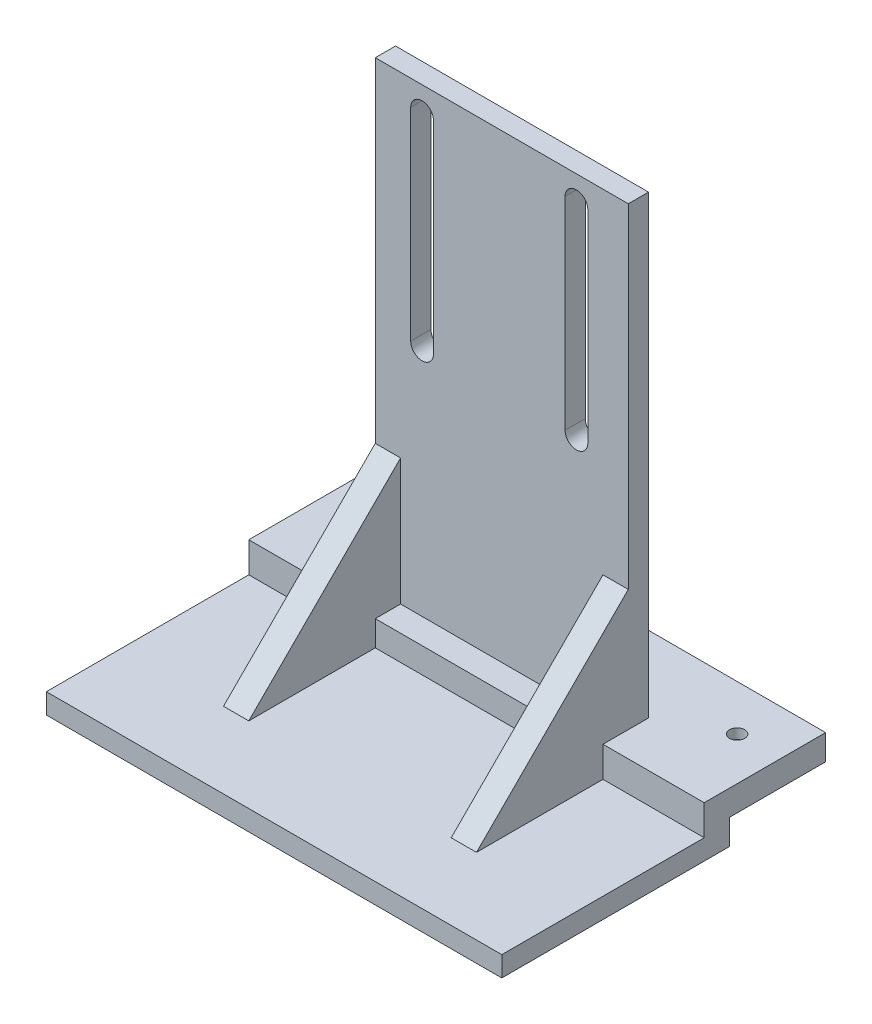
from build123d import *

# Parameters (mm, degrees)
ESQUISSE1_W             = 50
ESQUISSE1_H             = 95
BOSS_EXTRU_1_DEPTH      = 4
ESQUISSE2_W             = 50
ESQUISSE2_H             = 4
BOSS_EXTRU_2_DEPTH      = 5
ESQUISSE3_W             = 50
ESQUISSE3_H             = 5
BOSS_EXTRU_3_DEPTH      = 5
ESQUISSE4_W             = 50
ESQUISSE4_H             = 4
BOSS_EXTRU_4_DEPTH      = 40
ESQUISSE5_W             = 50
ESQUISSE5_H             = 5
BOSS_EXTRU_5_DEPTH      = 15
ENL_V_MAT_EXTRU_1_REACH = 21
BOSS_EXTRU_6_DEPTH      = 5
BOSS_EXTRU_7_DEPTH      = 5
BOSS_EXTRU_8_DEPTH      = 20
BOSS_EXTRU_9_DEPTH      = 20
ENL_V_MAT_EXTRU_2_REACH = 12
ESQUISSE12_R            = 1.5
ESQUISSE13_R            = 2
ENL_V_MAT_EXTRU_3_DEPTH = 3


with BuildPart() as part:
    # Esquisse1 → Boss.-Extru.1 (new body)
    with BuildSketch(Plane.XY):
        with Locations((-4.39396009, -13.572795505)):
            Rectangle(ESQUISSE1_W, ESQUISSE1_H)
    extrude(amount=BOSS_EXTRU_1_DEPTH)

    # Esquisse2 → Boss.-Extru.2 (add)
    with BuildSketch(Plane.XY.offset(4)):
        with Locations((-4.39396009, -59.072795505)):
            Rectangle(ESQUISSE2_W, ESQUISSE2_H)
    extrude(amount=BOSS_EXTRU_2_DEPTH)

    # Esquisse3 → Boss.-Extru.3 (add)
    with BuildSketch(Plane.XZ.offset(61.072795505)):
        with Locations((-4.39396009, 6.5)):
            Rectangle(ESQUISSE3_W, ESQUISSE3_H)
    extrude(amount=BOSS_EXTRU_3_DEPTH)

    # Esquisse4 → Boss.-Extru.4 (add)
    with BuildSketch(Plane.XY.offset(9)):
        with Locations((-4.39396009, -64.072795505)):
            Rectangle(ESQUISSE4_W, ESQUISSE4_H)
    extrude(amount=BOSS_EXTRU_4_DEPTH)

    # Esquisse5 → Boss.-Extru.5 (add)
    with BuildSketch(Plane(origin=(0, 0, 0), x_dir=(-1, 0, 0), z_dir=(0, 0, -1))):
        with Locations((4.39396009, -58.572795505)):
            Rectangle(ESQUISSE5_W, ESQUISSE5_H)
    extrude(amount=BOSS_EXTRU_5_DEPTH)

    # Esquisse6 → Enlèv. mat.-Extru.1 (cut, up to next)
    with BuildSketch(Plane.XY.offset(4), mode=Mode.PRIVATE) as enl_v_mat_extru_1_sk1:
        with BuildLine():
            Line((-17.89396009, 28.927204495), (-17.89396009, -11.072795505))
            ThreePointArc((-17.89396009, -11.072795505), (-20.14396009, -13.322795505), (-22.39396009, -11.072795505))
            Line((-22.39396009, -11.072795505), (-22.39396009, 28.927204495))
            ThreePointArc((-22.39396009, 28.927204495), (-20.14396009, 31.177204495), (-17.89396009, 28.927204495))
        make_face()
    enl_v_mat_extru_1_tool1 = extrude(enl_v_mat_extru_1_sk1.sketch, amount=-ENL_V_MAT_EXTRU_1_REACH, mode=Mode.PRIVATE) & part.part
    add(enl_v_mat_extru_1_tool1.solids().sort_by_distance((-20.14396, 8.927204, 4))[0], mode=Mode.SUBTRACT)
    # Esquisse6 → Enlèv. mat.-Extru.1 (cut, up to next)
    with BuildSketch(Plane.XY.offset(4), mode=Mode.PRIVATE) as enl_v_mat_extru_1_sk2:
        with BuildLine():
            Line((12.60603991, 28.927204495), (12.60603991, -11.072795505))
            ThreePointArc((12.60603991, -11.072795505), (10.35603991, -13.322795505), (8.10603991, -11.072795505))
            Line((8.10603991, -11.072795505), (8.10603991, 28.927204495))
            ThreePointArc((8.10603991, 28.927204495), (10.35603991, 31.177204495), (12.60603991, 28.927204495))
        make_face()
    enl_v_mat_extru_1_tool2 = extrude(enl_v_mat_extru_1_sk2.sketch, amount=-ENL_V_MAT_EXTRU_1_REACH, mode=Mode.PRIVATE) & part.part
    add(enl_v_mat_extru_1_tool2.solids().sort_by_distance((10.35604, 8.927204, 4))[0], mode=Mode.SUBTRACT)

    # Esquisse7 → Boss.-Extru.6 (add)
    with BuildSketch(Plane.ZY.offset(29.39396009)):
        Polygon((4, -32.072795505), (34, -62.072795505), (4, -62.072795505), align=None)
    extrude(amount=-BOSS_EXTRU_6_DEPTH)

    # Esquisse8 → Boss.-Extru.7 (add)
    with BuildSketch(Plane(origin=(20.60603991, 0, 0), x_dir=(0, 0, -1), z_dir=(1, 0, 0))):
        Polygon((-4, -32.072795505), (-34, -62.072795505), (-4, -62.072795505), align=None)
    extrude(amount=-BOSS_EXTRU_7_DEPTH)

    # Esquisse10 → Boss.-Extru.8 (add)
    with BuildSketch(Plane(origin=(20.60603991, 0, 0), x_dir=(0, 0, -1), z_dir=(1, 0, 0))):
        Polygon((-49, -62.072795505), (-49, -66.072795505), (-4, -66.072795505), (-4, -61.072795505), (15, -61.072795505), (15, -56.072795505), (0, -56.072795505), (-9, -56.072795505), (-9, -62.072795505), align=None)
    extrude(amount=BOSS_EXTRU_8_DEPTH)

    # Esquisse11 → Boss.-Extru.9 (add)
    with BuildSketch(Plane.ZY.offset(29.39396009)):
        Polygon((49, -66.072795505), (4, -66.072795505), (4, -61.072795505), (-15, -61.072795505), (-15, -56.072795505), (0, -56.072795505), (9, -56.072795505), (9, -62.072795505), (49, -62.072795505), align=None)
    extrude(amount=BOSS_EXTRU_9_DEPTH)

    # Esquisse12 → Enlèv. mat.-Extru.2 (cut, up to next)
    with BuildSketch(Plane(origin=(0, -56.072795505, 0), x_dir=(1, 0, 0), z_dir=(0, 1, 0)), mode=Mode.PRIVATE) as enl_v_mat_extru_2_sk1:
        with Locations((32.10603991, 6)):
            Circle(ESQUISSE12_R)
    enl_v_mat_extru_2_tool1 = extrude(enl_v_mat_extru_2_sk1.sketch, amount=-ENL_V_MAT_EXTRU_2_REACH, mode=Mode.PRIVATE) & part.part
    add(enl_v_mat_extru_2_tool1.solids().sort_by_distance((32.10604, -56.072796, -6))[0], mode=Mode.SUBTRACT)
    # Esquisse12 → Enlèv. mat.-Extru.2 (cut, up to next)
    with BuildSketch(Plane(origin=(0, -56.072795505, 0), x_dir=(1, 0, 0), z_dir=(0, 1, 0)), mode=Mode.PRIVATE) as enl_v_mat_extru_2_sk2:
        with Locations((-40.89396009, 6)):
            Circle(ESQUISSE12_R)
    enl_v_mat_extru_2_tool2 = extrude(enl_v_mat_extru_2_sk2.sketch, amount=-ENL_V_MAT_EXTRU_2_REACH, mode=Mode.PRIVATE) & part.part
    add(enl_v_mat_extru_2_tool2.solids().sort_by_distance((-40.89396, -56.072796, -6))[0], mode=Mode.SUBTRACT)

    # Esquisse13 → Enlèv. mat.-Extru.3 (cut)
    with BuildSketch(Plane.XZ.offset(61.072795505)):
        with Locations((32.10603991, -6)):
            Circle(ESQUISSE13_R)
        with Locations((-40.89396009, -6)):
            Circle(ESQUISSE13_R)
    extrude(amount=-ENL_V_MAT_EXTRU_3_DEPTH, mode=Mode.SUBTRACT)


solid = part.part
